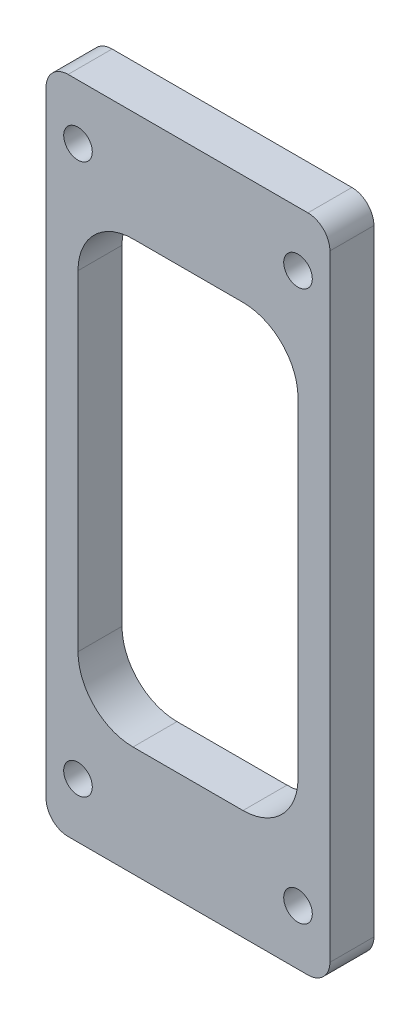
from build123d import *

# Parameters (mm, degrees)
SZKIC1_W                    = 25.8
SZKIC1_H                    = 60
DODANIE_WYCI_GNI_CIE1_DEPTH = 4
OTW_R_POD_RUB_M21_D         = 2.6
ZAOKR_GLENIE1_R             = 2
WYTNIJ_WYCI_GNI_CIE1_REACH  = 6


with BuildPart() as part:
    # Szkic1 → Dodanie-wyciągnięcie1 (new body)
    with BuildSketch(Plane.XY):
        Rectangle(SZKIC1_W, SZKIC1_H)
    extrude(amount=DODANIE_WYCI_GNI_CIE1_DEPTH)

    # Otwór pod śrubę M21 (through all)
    with Locations(Plane.XY.offset(4)):
        with Locations((-10, 25), (10, 25), (10, -25), (-10, -25)):
            Hole(OTW_R_POD_RUB_M21_D / 2)

    # Zaokrąglenie1
    zaokr_glenie1_edges = [part.edges().sort_by_distance(p)[0] for p in [
        (12.9, -30, 2),
        (-12.9, -30, 2),
        (-12.9, 30, 2),
        (12.9, 30, 2),
    ]]
    fillet(zaokr_glenie1_edges, radius=ZAOKR_GLENIE1_R)

    # Szkic5 → Wytnij-wyciągnięcie1 (cut, up to next)
    with BuildSketch(Plane.XY.offset(4), mode=Mode.PRIVATE) as wytnij_wyci_gni_cie1_sk1:
        with BuildLine():
            Line((5, 20), (-5, 20))
            ThreePointArc((-5, 20), (-8.535533906, 18.535533906), (-10, 15))
            Line((-10, 15), (-10, -15))
            ThreePointArc((-10, -15), (-8.535533906, -18.535533906), (-5, -20))
            Line((-5, -20), (5, -20))
            ThreePointArc((5, -20), (8.535533906, -18.535533906), (10, -15))
            Line((10, -15), (10, 15))
            ThreePointArc((10, 15), (8.535533906, 18.535533906), (5, 20))
        make_face()
    wytnij_wyci_gni_cie1_tool1 = extrude(wytnij_wyci_gni_cie1_sk1.sketch, amount=-WYTNIJ_WYCI_GNI_CIE1_REACH, mode=Mode.PRIVATE) & part.part
    add(wytnij_wyci_gni_cie1_tool1.solids().sort_by_distance((0, 0, 4))[0], mode=Mode.SUBTRACT)


solid = part.part
